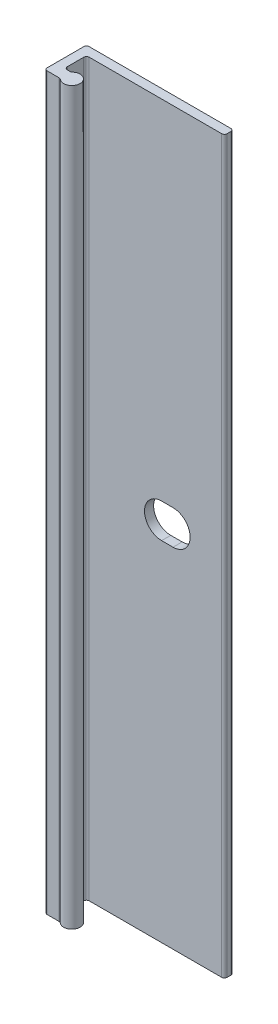
from build123d import *

# Parameters (mm, degrees)
BOSS_EXTRUDE1_DEPTH = 50.8
CUT_EXTRUDE1_DEPTH  = 2.27


with BuildPart() as part:
    # Sketch2 → Boss-Extrude1 (new body, symmetric)
    with BuildSketch(Plane(origin=(0, 0, 0), x_dir=(1, 0, 0), z_dir=(0, 1, 0))):
        with BuildLine():
            Line((0.381, 0), (20.066, 0))
            ThreePointArc((20.066, 0), (20.335407684, -0.111592316), (20.447, -0.381))
            Line((20.447, -0.381), (20.447, -0.889))
            ThreePointArc((20.447, -0.889), (20.335407684, -1.158407684), (20.066, -1.27))
            Line((20.066, -1.27), (1.651, -1.27))
            ThreePointArc((1.651, -1.27), (1.381592316, -1.381592316), (1.27, -1.651))
            Line((1.27, -1.651), (1.27, -3.937))
            ThreePointArc((1.27, -3.937), (1.381592316, -4.206407684), (1.651, -4.318))
            Line((1.651, -4.318), (2.03996875, -4.318))
            ThreePointArc((2.03996875, -4.318), (2.174672592, -4.293392866), (2.291976563, -4.22275))
            ThreePointArc((2.291976563, -4.22275), (4.191, -5.08), (2.291976563, -5.93725))
            ThreePointArc((2.291976563, -5.93725), (2.174672592, -5.866607134), (2.03996875, -5.842))
            Line((2.03996875, -5.842), (0.381, -5.842))
            ThreePointArc((0.381, -5.842), (0.111592316, -5.730407684), (0, -5.461))
            Line((0, -5.461), (0, -0.381))
            ThreePointArc((0, -0.381), (0.111592316, -0.111592316), (0.381, 0))
        make_face()
    extrude(amount=BOSS_EXTRUDE1_DEPTH, both=True)

    # Sketch7 → Cut-Extrude1 (cut, through all)
    with BuildSketch(Plane.XY.offset(1.27)):
        with BuildLine():
            Line((11.71575, 2.38125), (13.30325, 2.38125))
            ThreePointArc((13.30325, 2.38125), (15.6845, 0), (13.30325, -2.38125))
            Line((13.30325, -2.38125), (11.71575, -2.38125))
            ThreePointArc((11.71575, -2.38125), (9.3345, 0), (11.71575, 2.38125))
        make_face()
    extrude(amount=-CUT_EXTRUDE1_DEPTH, mode=Mode.SUBTRACT)


solid = part.part
